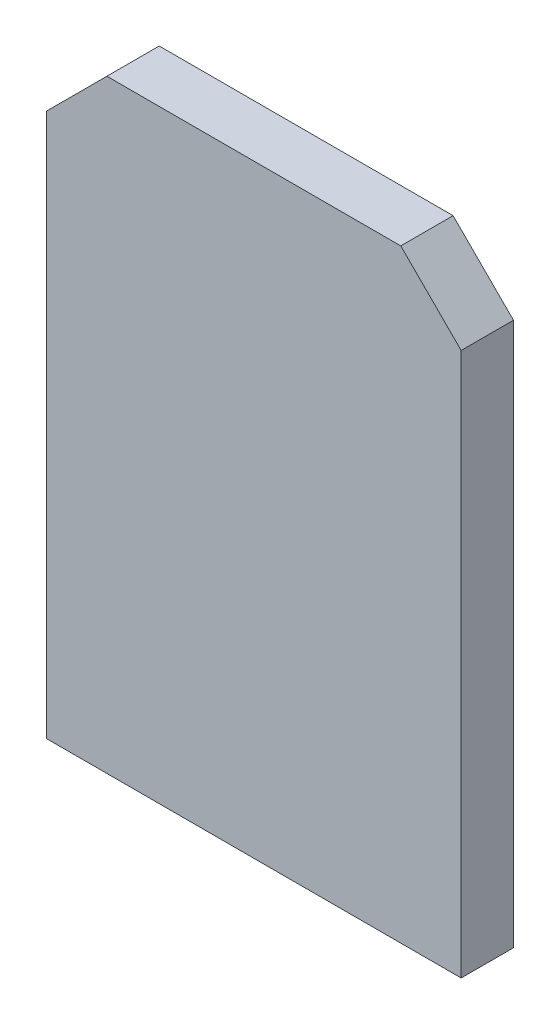
from build123d import *

# Parameters (mm, degrees)
EXTRUDE_1_DEPTH = 1.3


with BuildPart() as part:
    # Эскиз1 → Бобышка-Вытянуть1 (new body)
    with BuildSketch(Plane.XY):
        Polygon((-8.946267919, -3.08007909), (-10.446267919, -4.58007909), (-10.446267919, -18.08007909), (-0.146267919, -18.08007909), (-0.146267919, -4.58007909), (-1.646267919, -3.08007909), align=None)
    extrude(amount=EXTRUDE_1_DEPTH)


solid = part.part
